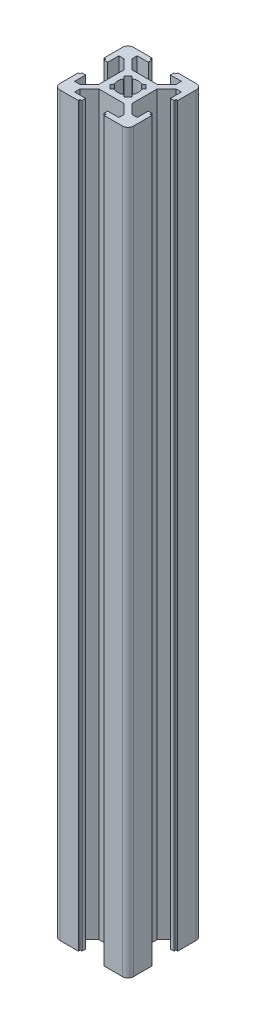
from build123d import *

# Parameters (mm, degrees)
DODANIE_WYCI_GNI_CIE1_DEPTH     = 807
SCHNITT_LINEAR_AUSTRAGEN1_DEPTH = 20


with BuildPart() as part:
    # Szkic1 → Dodanie-wyciągnięcie1 (new body)
    with BuildSketch(Plane(origin=(0, 0, 0), x_dir=(1, 0, 0), z_dir=(0, 1, 0))):
        with BuildLine():
            Line((-7.06, 6), (-4.5, 3.440546933))
            Line((-4.5, 3.440546933), (-4.5, 4.5))
            Line((-4.5, 4.5), (-3.440546933, 4.5))
            Line((-3.440546933, 4.5), (-6, 7.06))
            Line((-6, 7.06), (-6, 8.5))
            Line((-6, 8.5), (-3, 8.5))
            Line((-3, 8.5), (-3, 9.5))
            Line((-3, 9.5), (-3.5, 9.5))
            Line((-3.5, 9.5), (-3.5, 10))
            Line((-3.5, 10), (-8.5, 10))
            ThreePointArc((-8.5, 10), (-9.560660172, 9.560660172), (-10, 8.5))
            Line((-10, 8.5), (-10, 3.5))
            Line((-10, 3.5), (-9.5, 3.5))
            Line((-9.5, 3.5), (-9.5, 3))
            Line((-9.5, 3), (-8.5, 3))
            Line((-8.5, 3), (-8.5, 6))
            Line((-8.5, 6), (-7.06, 6))
        make_face()
        with BuildLine():
            Line((4.5, 4.5), (4.5, 3.440546933))
            Line((4.5, 3.440546933), (7.06, 6))
            Line((7.06, 6), (8.5, 6))
            Line((8.5, 6), (8.5, 3))
            Line((8.5, 3), (9.5, 3))
            Line((9.5, 3), (9.5, 3.5))
            Line((9.5, 3.5), (10, 3.5))
            Line((10, 3.5), (10, 8.5))
            ThreePointArc((10, 8.5), (9.560660172, 9.560660172), (8.5, 10))
            Line((8.5, 10), (3.5, 10))
            Line((3.5, 10), (3.5, 9.5))
            Line((3.5, 9.5), (3, 9.5))
            Line((3, 9.5), (3, 8.5))
            Line((3, 8.5), (6, 8.5))
            Line((6, 8.5), (6, 7.06))
            Line((6, 7.06), (3.440546933, 4.5))
            Line((3.440546933, 4.5), (4.5, 4.5))
        make_face()
        Polygon((3.440546933, -4.5), (4.5, -4.5), (4.5, -3.440546933), (4.5, 3.440546933), (4.5, 4.5), (3.440546933, 4.5), (-3.440546933, 4.5), (-4.5, 4.5), (-4.5, 3.440546933), (-4.5, -3.440546933), (-4.5, -4.5), (-3.440546933, -4.5), align=None)
        with BuildLine():
            Line((-3.00520382, 1.944543648), (-1.944543648, 3.00520382))
            Line((-1.944543648, 3.00520382), (-1.271309214, 2.438498079))
            ThreePointArc((-1.271309214, 2.438498079), (0, 2.75), (1.271309214, 2.438498079))
            Line((1.271309214, 2.438498079), (1.944543648, 3.00520382))
            Line((1.944543648, 3.00520382), (3.00520382, 1.944543648))
            Line((3.00520382, 1.944543648), (2.438498079, 1.271309214))
            ThreePointArc((2.438498079, 1.271309214), (2.670989491, 0.654457899), (2.75, 0))
            ThreePointArc((2.75, 0), (2.670989491, -0.654457899), (2.438498079, -1.271309214))
            Line((2.438498079, -1.271309214), (3.00520382, -1.944543648))
            Line((3.00520382, -1.944543648), (1.944543648, -3.00520382))
            Line((1.944543648, -3.00520382), (1.271309214, -2.438498079))
            ThreePointArc((1.271309214, -2.438498079), (0, -2.75), (-1.271309214, -2.438498079))
            Line((-1.271309214, -2.438498079), (-1.944543648, -3.00520382))
            Line((-1.944543648, -3.00520382), (-3.00520382, -1.944543648))
            Line((-3.00520382, -1.944543648), (-2.438498079, -1.271309214))
            ThreePointArc((-2.438498079, -1.271309214), (-2.75, 0), (-2.438498079, 1.271309214))
            Line((-2.438498079, 1.271309214), (-3.00520382, 1.944543648))
        make_face(mode=Mode.SUBTRACT)
        with BuildLine():
            Line((-6, -7.06), (-3.440546933, -4.5))
            Line((-3.440546933, -4.5), (-4.5, -4.5))
            Line((-4.5, -4.5), (-4.5, -3.440546933))
            Line((-4.5, -3.440546933), (-7.06, -6))
            Line((-7.06, -6), (-8.5, -6))
            Line((-8.5, -6), (-8.5, -3))
            Line((-8.5, -3), (-9.5, -3))
            Line((-9.5, -3), (-9.5, -3.5))
            Line((-9.5, -3.5), (-10, -3.5))
            Line((-10, -3.5), (-10, -8.5))
            ThreePointArc((-10, -8.5), (-9.560660172, -9.560660172), (-8.5, -10))
            Line((-8.5, -10), (-3.5, -10))
            Line((-3.5, -10), (-3.5, -9.5))
            Line((-3.5, -9.5), (-3, -9.5))
            Line((-3, -9.5), (-3, -8.5))
            Line((-3, -8.5), (-6, -8.5))
            Line((-6, -8.5), (-6, -7.06))
        make_face()
        with BuildLine():
            Line((4.5, -3.440546933), (4.5, -4.5))
            Line((4.5, -4.5), (3.440546933, -4.5))
            Line((3.440546933, -4.5), (6, -7.06))
            Line((6, -7.06), (6, -8.5))
            Line((6, -8.5), (3, -8.5))
            Line((3, -8.5), (3, -9.5))
            Line((3, -9.5), (3.5, -9.5))
            Line((3.5, -9.5), (3.5, -10))
            Line((3.5, -10), (8.5, -10))
            ThreePointArc((8.5, -10), (9.560660172, -9.560660172), (10, -8.5))
            Line((10, -8.5), (10, -3.5))
            Line((10, -3.5), (9.5, -3.5))
            Line((9.5, -3.5), (9.5, -3))
            Line((9.5, -3), (8.5, -3))
            Line((8.5, -3), (8.5, -6))
            Line((8.5, -6), (7.06, -6))
            Line((7.06, -6), (4.5, -3.440546933))
        make_face()
    extrude(amount=DODANIE_WYCI_GNI_CIE1_DEPTH)

    # Skizze1 → Schnitt-Linear austragen1 (cut, symmetric)
    with BuildSketch(Plane.XY):
        Polygon((-83.496312338, 200), (63.910757592, 200), (55.14879889, 860.754768005), (-83.496312338, 858.91626029), align=None)
    extrude(amount=SCHNITT_LINEAR_AUSTRAGEN1_DEPTH, both=True, mode=Mode.SUBTRACT)


solid = part.part
